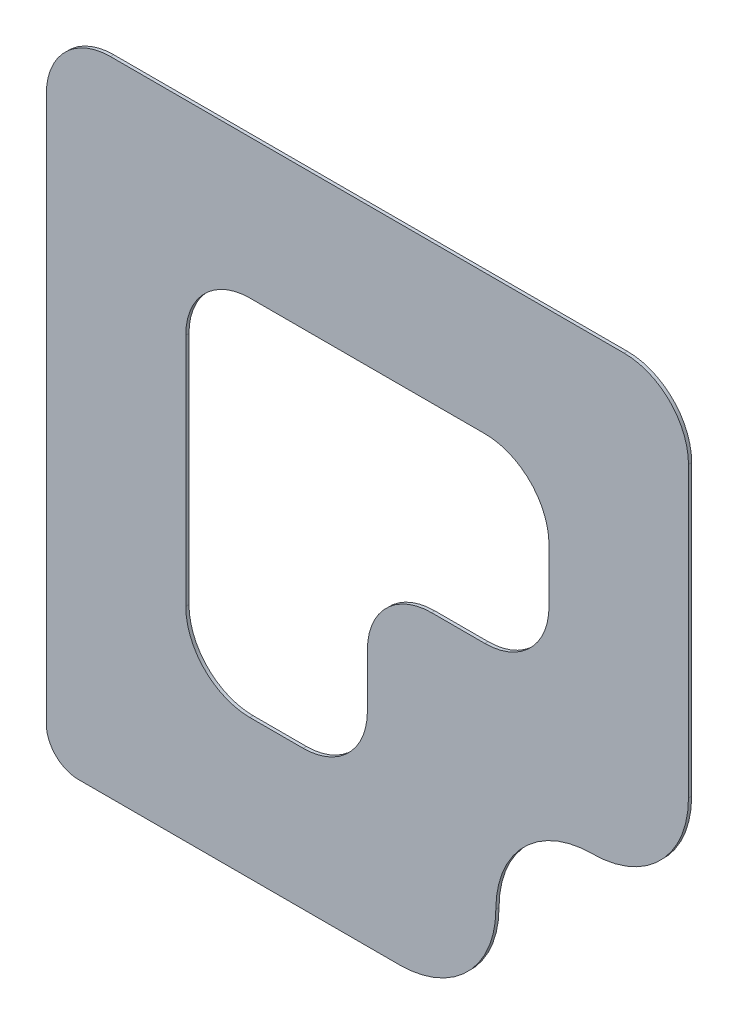
from build123d import *

# Parameters (mm, degrees)
SALIENTE_EXTRUIR1_DEPTH = 0.1


with BuildPart() as part:
    # Model → Saliente-Extruir1 (new body)
    with BuildSketch(Plane.XY):
        with BuildLine():
            Line((20.5, 22), (28.5, 22))
            Line((28.5, 22), (30.5, 22))
            ThreePointArc((30.5, 22), (32.621320344, 22.878679656), (33.5, 25))
            ThreePointArc((33.5, 25), (34.378679656, 27.121320344), (36.5, 28))
            ThreePointArc((36.5, 28), (38.621320344, 28.878679656), (39.5, 31))
            Line((39.5, 31), (39.5, 33))
            Line((39.5, 33), (39.5, 40))
            ThreePointArc((39.5, 40), (38.914213562, 41.414213562), (37.5, 42))
            Line((37.5, 42), (21.5, 42))
            ThreePointArc((21.5, 42), (20.085786438, 41.414213562), (19.5, 40))
            Line((19.5, 40), (19.5, 23))
            ThreePointArc((19.5, 23), (19.792893219, 22.292893219), (20.5, 22))
        make_face()
        with BuildLine():
            Line((31.5, 32), (33.156854249, 32))
            ThreePointArc((33.156854249, 32), (34.571067812, 32.585786438), (35.156854249, 34))
            Line((35.156854249, 34), (35.156854249, 35.656854249))
            ThreePointArc((35.156854249, 35.656854249), (34.571067812, 37.071067812), (33.156854249, 37.656854249))
            Line((33.156854249, 37.656854249), (25.843145751, 37.656854249))
            ThreePointArc((25.843145751, 37.656854249), (24.428932188, 37.071067812), (23.843145751, 35.656854249))
            Line((23.843145751, 35.656854249), (23.843145751, 28.343145751))
            ThreePointArc((23.843145751, 28.343145751), (24.428932188, 26.928932188), (25.843145751, 26.343145751))
            Line((25.843145751, 26.343145751), (27.5, 26.343145751))
            ThreePointArc((27.5, 26.343145751), (28.914213562, 26.928932188), (29.5, 28.343145751))
            Line((29.5, 28.343145751), (29.5, 30))
            ThreePointArc((29.5, 30), (30.085786438, 31.414213562), (31.5, 32))
        make_face(mode=Mode.SUBTRACT)
    extrude(amount=SALIENTE_EXTRUIR1_DEPTH)


solid = part.part
